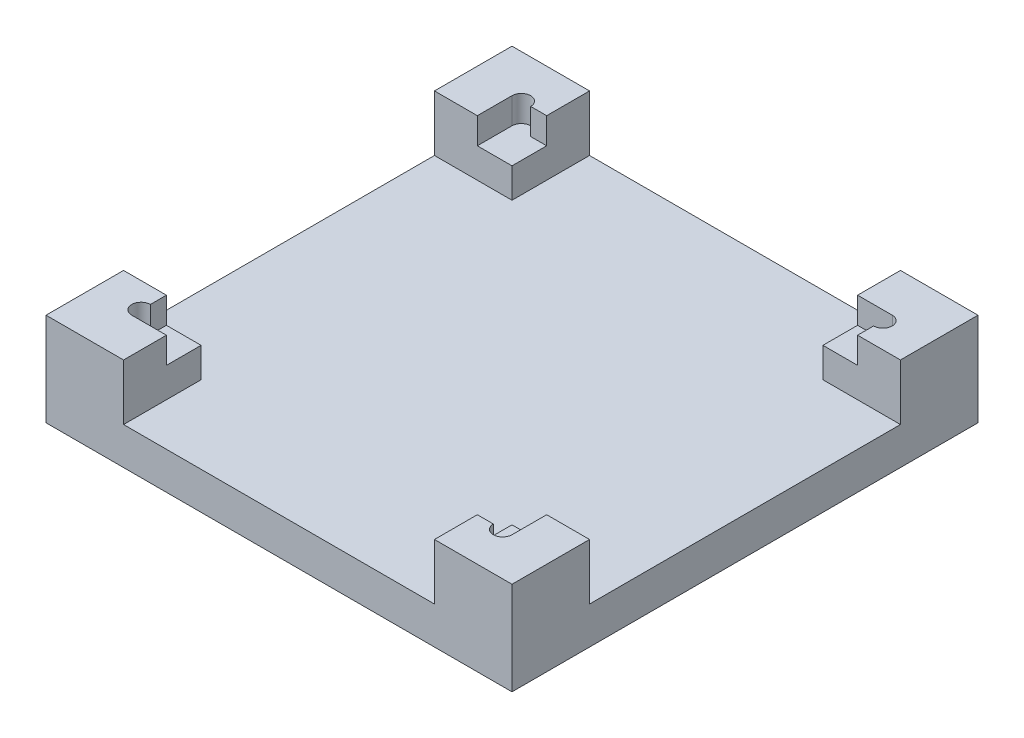
from build123d import *

# Parameters (mm, degrees)
SKETCH1_W           = 125
SKETCH1_H           = 125
BOSS_EXTRUDE1_DEPTH = 25
SKETCH2_W           = 102
SKETCH2_H           = 102
CUT_EXTRUDE1_DEPTH  = 15
SKETCH4_W           = 83.4
SKETCH4_H           = 11.5
SKETCH4_W_2         = 11.5
SKETCH4_H_2         = 83.4
CUT_EXTRUDE2_DEPTH  = 15
SKETCH5_W           = 9.3
SKETCH5_H           = 9.3
BOSS_EXTRUDE2_DEPTH = 8
CUT_EXTRUDE3_DEPTH  = 7


with BuildPart() as part:
    # Sketch1 → Boss-Extrude1 (new body)
    with BuildSketch(Plane(origin=(0, 0, 0), x_dir=(1, 0, 0), z_dir=(0, 1, 0))):
        with Locations((62.5, 62.5)):
            Rectangle(SKETCH1_W, SKETCH1_H)
    extrude(amount=BOSS_EXTRUDE1_DEPTH)

    # Sketch2 → Cut-Extrude1 (cut)
    with BuildSketch(Plane(origin=(0, 25, 0), x_dir=(1, 0, 0), z_dir=(0, 1, 0))):
        with Locations((62.5, 62.5)):
            Rectangle(SKETCH2_W, SKETCH2_H)
    extrude(amount=-CUT_EXTRUDE1_DEPTH, mode=Mode.SUBTRACT)

    # Sketch4 → Cut-Extrude2 (cut)
    with BuildSketch(Plane(origin=(0, 25, 0), x_dir=(1, 0, 0), z_dir=(0, 1, 0))):
        with Locations((62.5, 119.25)):
            Rectangle(SKETCH4_W, SKETCH4_H)
        with Locations((5.75, 62.5)):
            Rectangle(SKETCH4_W_2, SKETCH4_H_2)
        with Locations((62.5, 5.75)):
            Rectangle(SKETCH4_W, SKETCH4_H)
        with Locations((119.25, 62.5)):
            Rectangle(SKETCH4_W_2, SKETCH4_H_2)
    extrude(amount=-CUT_EXTRUDE2_DEPTH, mode=Mode.SUBTRACT)

    # Sketch5 → Boss-Extrude2 (add)
    with BuildSketch(Plane(origin=(0, 10, 0), x_dir=(1, 0, 0), z_dir=(0, 1, 0))):
        with Locations((108.85, 16.15)):
            Rectangle(SKETCH5_W, SKETCH5_H)
        with Locations((16.15, 16.15)):
            Rectangle(SKETCH5_W, SKETCH5_H)
        with Locations((16.15, 108.85)):
            Rectangle(SKETCH5_W, SKETCH5_H)
        with Locations((108.85, 108.85)):
            Rectangle(SKETCH5_W, SKETCH5_H)
    extrude(amount=BOSS_EXTRUDE2_DEPTH)

    # Sketch6 → Cut-Extrude3 (cut)
    with BuildSketch(Plane(origin=(0, 25, 0), x_dir=(1, 0, 0), z_dir=(0, 1, 0))):
        with BuildLine():
            Line((11.5, 11.5), (11.5, 16.5))
            ThreePointArc((11.5, 16.5), (9, 14), (11.5, 11.5))
        make_face()
        with BuildLine():
            Line((113.5, 11.5), (108.5, 11.5))
            ThreePointArc((108.5, 11.5), (111, 9), (113.5, 11.5))
        make_face()
        with BuildLine():
            Line((113.5, 108.5), (113.5, 113.5))
            ThreePointArc((113.5, 113.5), (116, 111), (113.5, 108.5))
        make_face()
        with BuildLine():
            Line((11.5, 113.5), (16.5, 113.5))
            ThreePointArc((16.5, 113.5), (14, 116), (11.5, 113.5))
        make_face()
    extrude(amount=-CUT_EXTRUDE3_DEPTH, mode=Mode.SUBTRACT)


solid = part.part
